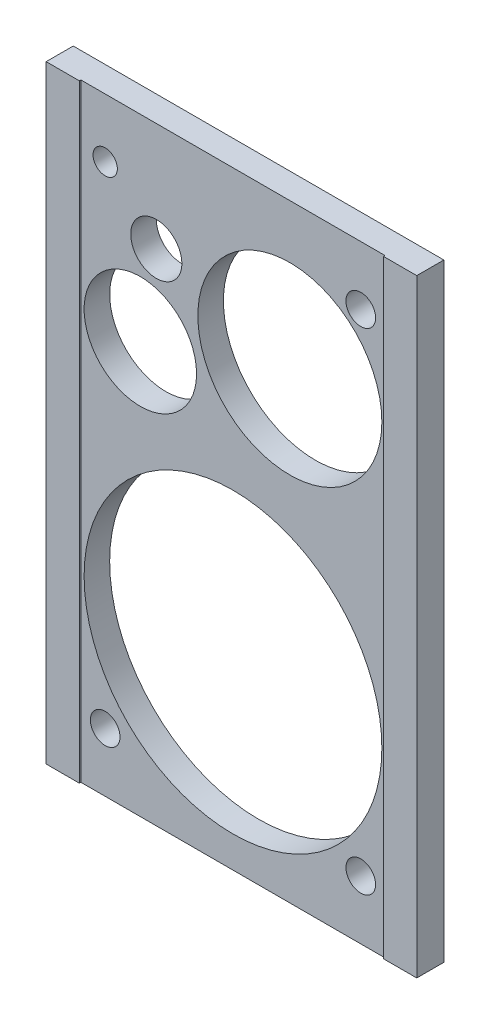
from build123d import *

# Parameters (mm, degrees)
SKETCH1_W           = 145
SKETCH1_H           = 238
SKETCH1_R           = 5.8
SKETCH1_R_2         = 22
SKETCH1_R_3         = 36
SKETCH1_R_4         = 58.25
SKETCH1_R_5         = 10
SKETCH1_R_6         = 4.75
BOSS_EXTRUDE1_DEPTH = 10
SKETCH2_W           = 13
SKETCH2_H           = 238
BOSS_EXTRUDE2_DEPTH = 0.6


with BuildPart() as part:
    # Sketch1 → Boss-Extrude1 (new body)
    with BuildSketch(Plane.XY):
        Rectangle(SKETCH1_W, SKETCH1_H)
        with Locations((50, 96)):
            Circle(SKETCH1_R, mode=Mode.SUBTRACT)
        with Locations((50, -96)):
            Circle(SKETCH1_R, mode=Mode.SUBTRACT)
        with Locations((-50, -96)):
            Circle(SKETCH1_R, mode=Mode.SUBTRACT)
        with Locations((-36.25, 42)):
            Circle(SKETCH1_R_2, mode=Mode.SUBTRACT)
        with Locations((22.25, 62)):
            Circle(SKETCH1_R_3, mode=Mode.SUBTRACT)
        with Locations((0, -48.5)):
            Circle(SKETCH1_R_4, mode=Mode.SUBTRACT)
        with Locations((-30, 76.5)):
            Circle(SKETCH1_R_5, mode=Mode.SUBTRACT)
        with Locations((-50, 96)):
            Circle(SKETCH1_R_6, mode=Mode.SUBTRACT)
    extrude(amount=BOSS_EXTRUDE1_DEPTH)

    # Sketch2 → Boss-Extrude2 (add)
    with BuildSketch(Plane.XY.offset(10)):
        with Locations((-66, 0)):
            Rectangle(SKETCH2_W, SKETCH2_H)
        with Locations((66, 0)):
            Rectangle(SKETCH2_W, SKETCH2_H)
    extrude(amount=BOSS_EXTRUDE2_DEPTH)


solid = part.part
